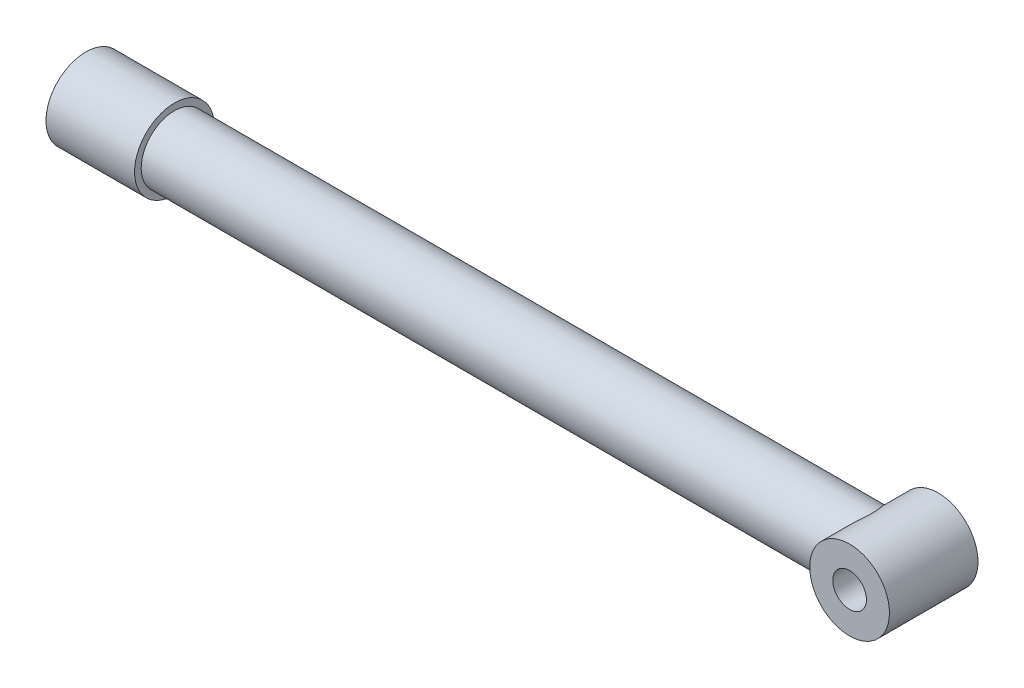
from build123d import *

# Parameters (mm, degrees)
SKETCH2_R               = 90
SKETCH2_R_2             = 38
BOSS_EXTRUDE1_DEPTH     = 100
CUT_EXTRUDE1_DEPTH      = 1920.720031781
CUT_EXTRUDE1_DEPTH_BACK = 1920.720031781
SKETCH2_2_R             = 38


with BuildPart() as part:
    # Sketch1 → Revolve2 (revolve)
    with BuildSketch(Plane.XY):
        Polygon((1825, 0), (1825, 75), (200, 75), (200, 90), (0, 90), (0, 51), (1750, 51), (1750, 0), align=None)
    revolve(axis=Axis((0, 0, 0), (1, 0, 0)))

    # Sketch2 → Boss-Extrude1 (add, symmetric)
    with BuildSketch(Plane.XY):
        with Locations((1825, 0)):
            Circle(SKETCH2_R)
        with Locations((1825, 0)):
            Circle(SKETCH2_R_2, mode=Mode.SUBTRACT)
    extrude(amount=BOSS_EXTRUDE1_DEPTH, both=True)

    # Sketch2_2 → Cut-Extrude1 (cut, two sides: drawn at the far end of the back side and taken through both)
    with BuildSketch(Plane.XY.offset(-CUT_EXTRUDE1_DEPTH_BACK)):
        with Locations((1825, 0)):
            Circle(SKETCH2_2_R)
    extrude(amount=CUT_EXTRUDE1_DEPTH + CUT_EXTRUDE1_DEPTH_BACK, mode=Mode.SUBTRACT)


solid = part.part
